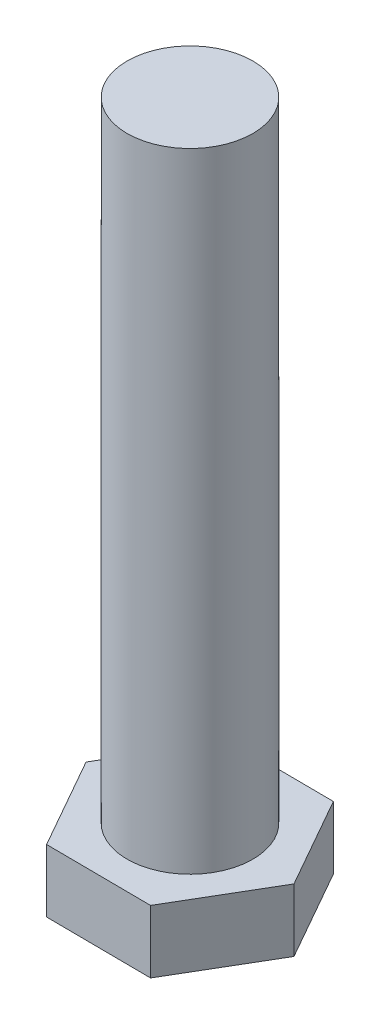
from build123d import *

# Parameters (mm, degrees)
SKETCH1_R           = 1.5
BOSS_EXTRUDE1_DEPTH = 15
BOSS_EXTRUDE2_DEPTH = 1.5


with BuildPart() as part:
    # Sketch1 → Boss-Extrude1 (new body)
    with BuildSketch(Plane(origin=(0, 0, 0), x_dir=(1, 0, 0), z_dir=(0, 1, 0))):
        Circle(SKETCH1_R)
    extrude(amount=BOSS_EXTRUDE1_DEPTH)

    # Sketch2 → Boss-Extrude2 (add)
    with BuildSketch(Plane.XZ):
        Polygon((2.5, 0.018896825), (1.23363487, 2.174511922), (-1.26636513, 2.155615097), (-2.5, -0.018896825), (-1.23363487, -2.174511922), (1.26636513, -2.155615097), align=None)
    extrude(amount=BOSS_EXTRUDE2_DEPTH)


solid = part.part
